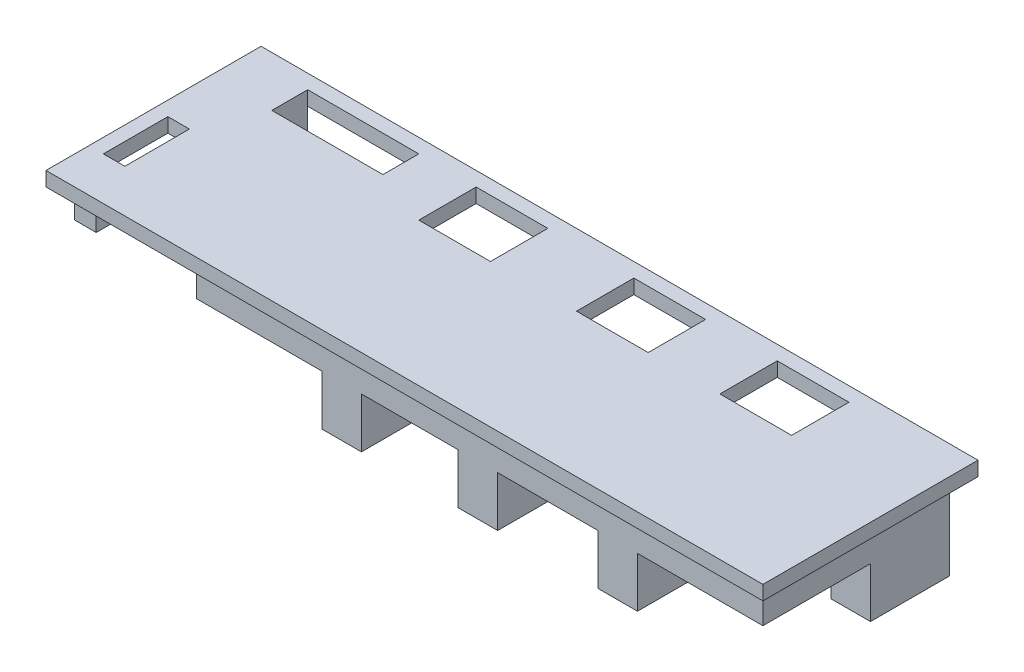
from build123d import *

# Parameters (mm, degrees)
SKETCH1_W            = 100
SKETCH1_H            = 30
SKETCH1_W_2          = 3
SKETCH1_H_2          = 9
SKETCH1_W_3          = 10
SKETCH1_H_3          = 8
SKETCH1_W_4          = 15.5
SKETCH1_H_4          = 5
BOSS_EXTRUDE3_DEPTH  = 2
SKETCH2_W            = 5.5
SKETCH2_H            = 11
BOSS_EXTRUDE4_DEPTH  = 12
BOSS_EXTRUDE5_DEPTH  = 9.5
SKETCH9_W            = 3
SKETCH9_H            = 3
BOSS_EXTRUDE17_DEPTH = 4
SKETCH12_W           = 79
SKETCH12_H           = 15
BOSS_EXTRUDE22_DEPTH = 5
SKETCH13_W           = 5.5
SKETCH13_H           = 13
BOSS_EXTRUDE23_DEPTH = 7


with BuildPart() as part:
    # Sketch1 → Boss-Extrude3 (new body)
    with BuildSketch(Plane(origin=(0, 0, 0), x_dir=(1, 0, 0), z_dir=(0, 1, 0))):
        with Locations((50, 15)):
            Rectangle(SKETCH1_W, SKETCH1_H)
        with Locations((3.5, 10.5)):
            Rectangle(SKETCH1_W_2, SKETCH1_H_2, mode=Mode.SUBTRACT)
        with Locations((79, 24)):
            Rectangle(SKETCH1_W_3, SKETCH1_H_3, mode=Mode.SUBTRACT)
        with Locations((59, 24)):
            Rectangle(SKETCH1_W_3, SKETCH1_H_3, mode=Mode.SUBTRACT)
        with Locations((37, 24)):
            Rectangle(SKETCH1_W_3, SKETCH1_H_3, mode=Mode.SUBTRACT)
        with Locations((16.25, 25.5)):
            Rectangle(SKETCH1_W_4, SKETCH1_H_4, mode=Mode.SUBTRACT)
    extrude(amount=-BOSS_EXTRUDE3_DEPTH)

    # Sketch2 → Boss-Extrude4 (add)
    with BuildSketch(Plane.XZ.offset(2)):
        with Locations((95.25, -22.5)):
            Rectangle(SKETCH2_W, SKETCH2_H)
    extrude(amount=BOSS_EXTRUDE4_DEPTH)

    # Sketch3 → Boss-Extrude5 (add)
    with BuildSketch(Plane.XZ.offset(2)):
        Polygon((24, -17), (24, -23), (8.5, -23), (8.5, -28), (2, -28), (2, -17), align=None)
    extrude(amount=BOSS_EXTRUDE5_DEPTH)

    # Sketch9 → Boss-Extrude17 (add)
    with BuildSketch(Plane.XZ.offset(2)):
        with Locations((3.5, -3.5)):
            Rectangle(SKETCH9_W, SKETCH9_H)
    extrude(amount=BOSS_EXTRUDE17_DEPTH)

    # Sketch12 → Boss-Extrude22 (add)
    with BuildSketch(Plane.XZ.offset(2)):
        with Locations((58.5, -9.5)):
            Rectangle(SKETCH12_W, SKETCH12_H)
    extrude(amount=BOSS_EXTRUDE22_DEPTH)

    # Sketch13 → Boss-Extrude23 (add)
    with BuildSketch(Plane.XZ.offset(7)):
        with Locations((39.25, -8.5)):
            Rectangle(SKETCH13_W, SKETCH13_H)
        with Locations((58.25, -8.5)):
            Rectangle(SKETCH13_W, SKETCH13_H)
        with Locations((77.75, -8.5)):
            Rectangle(SKETCH13_W, SKETCH13_H)
    extrude(amount=BOSS_EXTRUDE23_DEPTH)


solid = part.part
